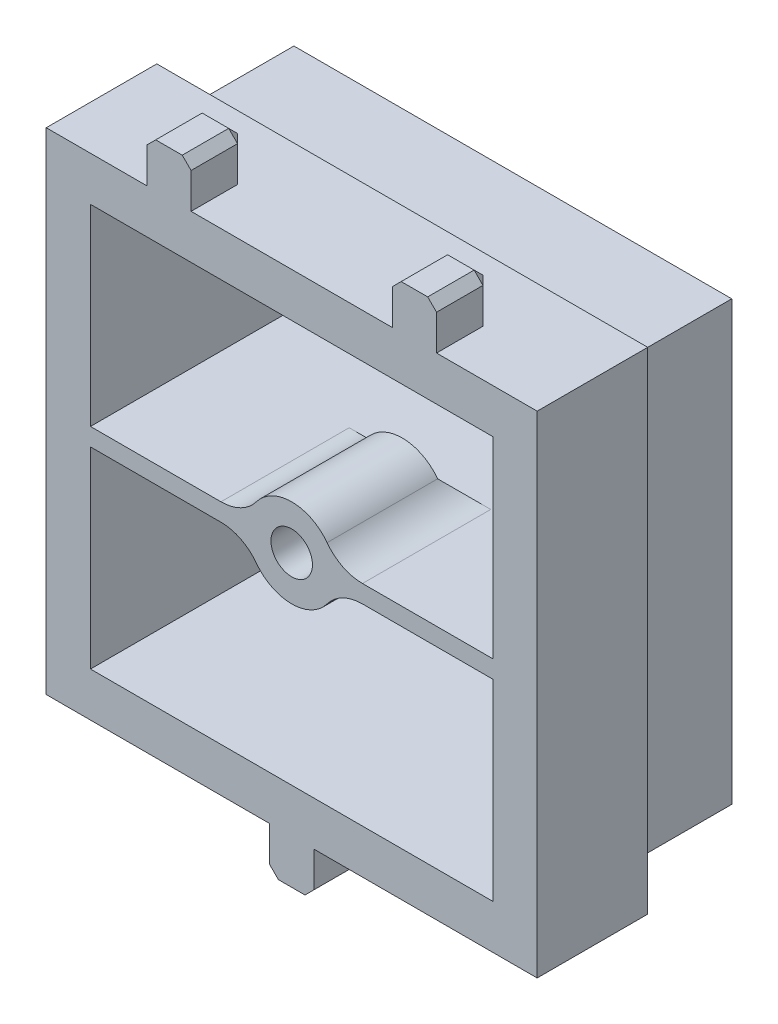
from build123d import *

# Parameters (mm, degrees)
SKETCH1_W                 = 12.573
SKETCH1_H                 = 12.573
SKETCH1_W_2               = 11.557
SKETCH1_H_2               = 11.557
EXTRUDE_THIN1_DEPTH       = 6.35
SKETCH1_4_W               = 12.573
SKETCH1_4_H               = 0.508
EXTRUDE_THIN2_DEPTH       = 6.35
SKETCH2_W                 = 14.097
SKETCH2_H                 = 14.097
SKETCH2_W_2               = 12.573
SKETCH2_H_2               = 12.573
BOSS_EXTRUDE1_DEPTH       = 3.175
SKETCH3_R                 = 1.27
BOSS_EXTRUDE2_DEPTH       = 3.175
FILLET2_R                 = 1.27
CHAMFER1_SIZE             = 0.508
F_0_80_TAPPED_HOLE1_D     = 1.19126
F_0_80_TAPPED_HOLE1_DEPTH = 3.302
F_0_80_TAPPED_HOLE1_TIP   = 0.357890611
SKETCH6_W                 = 1.27
SKETCH6_H                 = 1.27
EXTRUDE_THIN3_DEPTH       = 1.5875
CHAMFER2_SIZE             = 0.254


with BuildPart() as part:
    # Sketch1 → Extrude-Thin1 (new body)
    with BuildSketch(Plane.XY):
        with Locations((-12.7, -106.3625)):
            Rectangle(SKETCH1_W, SKETCH1_H)
        with Locations((-12.7, -106.3625)):
            Rectangle(SKETCH1_W_2, SKETCH1_H_2, mode=Mode.SUBTRACT)
    extrude(amount=EXTRUDE_THIN1_DEPTH)

    # Sketch1_4 → Extrude-Thin2 (add, through all)
    with BuildSketch(Plane.XY):
        with Locations((-12.7, -106.3625)):
            Rectangle(SKETCH1_4_W, SKETCH1_4_H)
    extrude(amount=EXTRUDE_THIN2_DEPTH)

    # Sketch2 → Boss-Extrude1 (add)
    with BuildSketch(Plane.XY.offset(6.35)):
        with Locations((-12.7, -106.3625)):
            Rectangle(SKETCH2_W, SKETCH2_H)
        with Locations((-12.7, -106.3625)):
            Rectangle(SKETCH2_W_2, SKETCH2_H_2, mode=Mode.SUBTRACT)
    extrude(amount=-BOSS_EXTRUDE1_DEPTH)

    # Sketch3 → Boss-Extrude2 (add)
    with BuildSketch(Plane.XY.offset(6.35)):
        with Locations((-12.7, -106.3625)):
            Circle(SKETCH3_R)
    extrude(amount=-BOSS_EXTRUDE2_DEPTH)

    # Fillet2
    fillet2_edges = [part.edges().sort_by_distance(p)[0] for p in [
        (-13.944340789, -106.6165, 4.7625),
        (-11.455659211, -106.6165, 4.7625),
        (-11.455659211, -106.1085, 4.7625),
        (-13.944340789, -106.1085, 4.7625),
    ]]
    fillet(fillet2_edges, radius=FILLET2_R)

    # Chamfer1
    chamfer1_edges = [part.edges().sort_by_distance(p)[0] for p in [
        (-12.7, -106.6165, 3.175),
        (-12.7, -106.1085, 3.175),
    ]]
    chamfer(chamfer1_edges, length=CHAMFER1_SIZE)

    # 0-80 Tapped Hole1
    with Locations(Plane.XY.offset(6.35)):
        with Locations((-12.7, -106.3625)):
            Hole(F_0_80_TAPPED_HOLE1_D / 2, depth=F_0_80_TAPPED_HOLE1_DEPTH)
            with Locations((0, 0, -(F_0_80_TAPPED_HOLE1_DEPTH + F_0_80_TAPPED_HOLE1_TIP / 2))):  # 118° drill point
                Cone(0, F_0_80_TAPPED_HOLE1_D / 2, F_0_80_TAPPED_HOLE1_TIP, mode=Mode.SUBTRACT)

    # Sketch6 → Extrude-Thin3 (add)
    with BuildSketch(Plane.XY.offset(6.35)):
        with Locations((-12.7, -114.046)):
            Rectangle(SKETCH6_W, SKETCH6_H)
        with Locations((-9.17575, -98.679)):
            Rectangle(SKETCH6_W, SKETCH6_H)
        with Locations((-16.22425, -98.679)):
            Rectangle(SKETCH6_W, SKETCH6_H)
    extrude(amount=-EXTRUDE_THIN3_DEPTH)

    # Chamfer2
    chamfer2_edges = [part.edges().sort_by_distance(p)[0] for p in [
        (-12.7, -114.681, 4.7625),
        (-12.065, -114.046, 4.7625),
        (-13.335, -114.046, 4.7625),
        (-8.54075, -98.044, 5.55625),
        (-9.81075, -98.044, 5.55625),
        (-16.85925, -98.044, 5.55625),
        (-15.58925, -98.044, 5.55625),
        (-13.335, -114.681, 5.55625),
        (-12.065, -114.681, 5.55625),
        (-9.81075, -98.679, 4.7625),
        (-8.54075, -98.679, 4.7625),
        (-9.17575, -98.044, 4.7625),
        (-16.85925, -98.679, 4.7625),
        (-16.22425, -98.044, 4.7625),
        (-15.58925, -98.679, 4.7625),
    ]]
    chamfer(chamfer2_edges, length=CHAMFER2_SIZE)


solid = part.part
